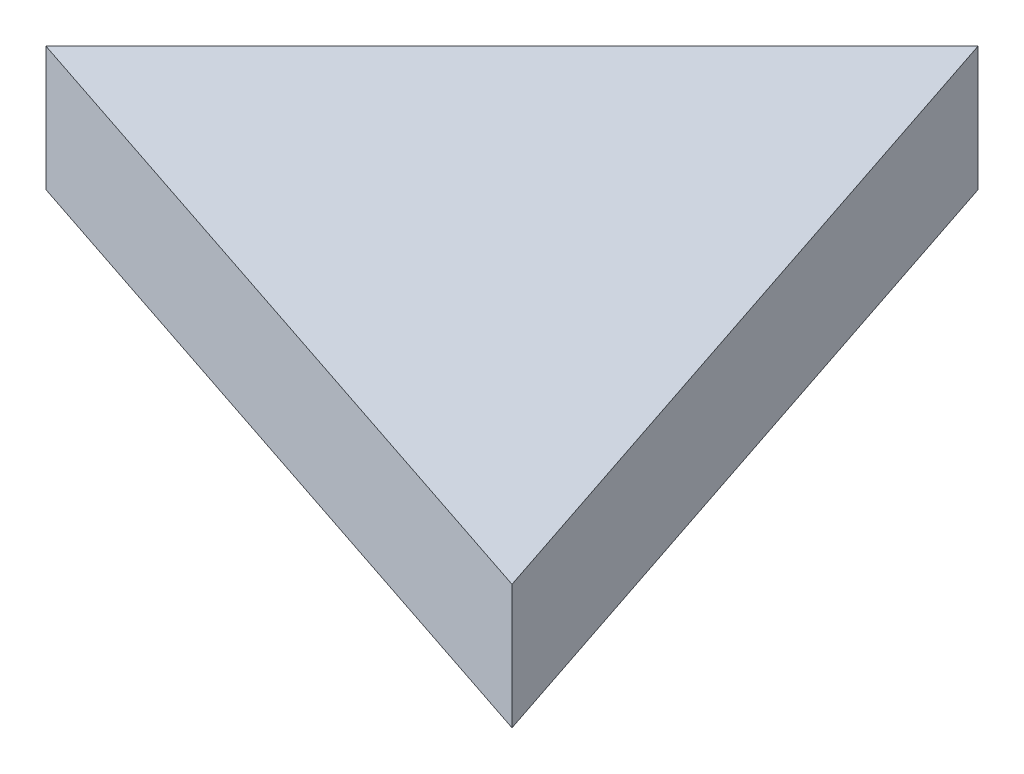
from build123d import *

# Parameters (mm, degrees)
EXTRUDE_E_DEPTH = 6.4


with BuildPart() as part:
    # puzzle plan_7 → Extrude E (new body)
    with BuildSketch(Plane(origin=(0, 0, 0), x_dir=(1, 0, 0), z_dir=(0, 1, 0))):
        Polygon((52, 72), (28, 48), (50, 40.666666667), (64, 36), align=None)
    extrude(amount=EXTRUDE_E_DEPTH)


solid = part.part
